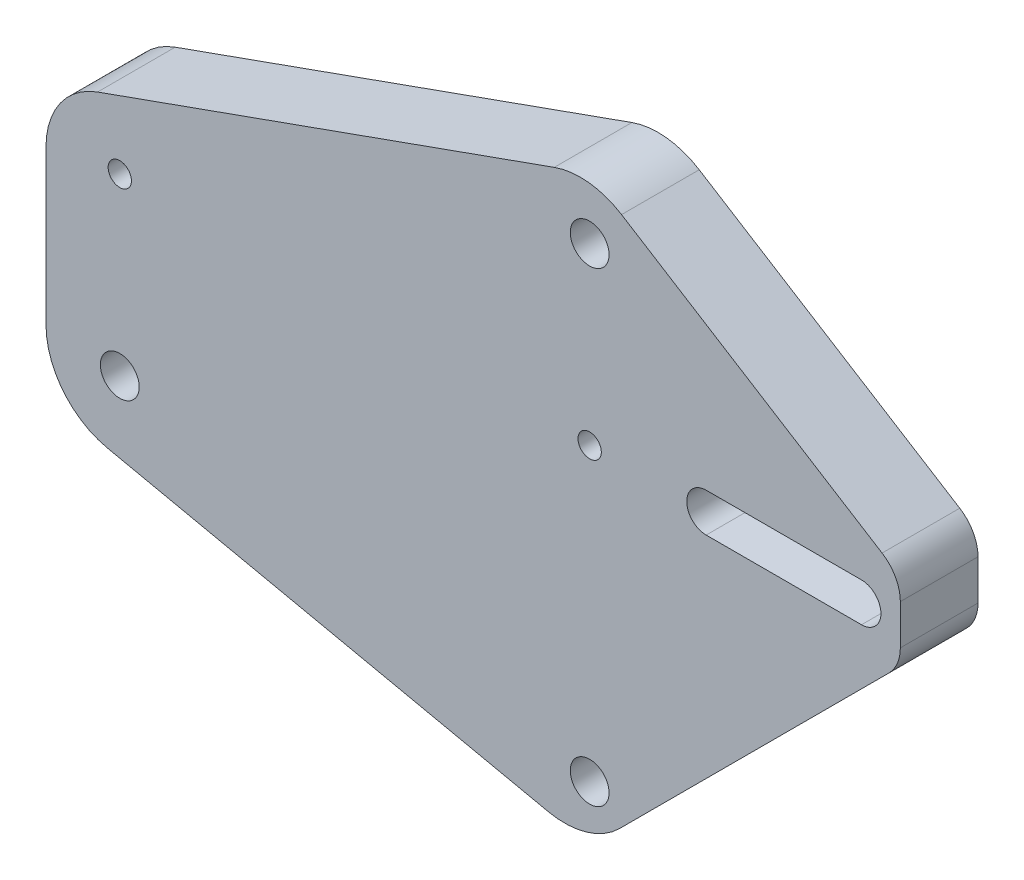
from build123d import *

# Parameters (mm, degrees)
SKETCH1_R           = 1.5
SKETCH1_R_2         = 2.5
BOSS_EXTRUDE2_DEPTH = 10


with BuildPart() as part:
    # Sketch1 → Boss-Extrude2 (new body)
    with BuildSketch(Plane.XY):
        with BuildLine():
            Line((-44.558562685, 33.371941898), (-103.36336397, 12.370227154))
            ThreePointArc((-103.36336397, 12.370227154), (-108.174155605, 8.713292405), (-110, 2.952808038))
            Line((-110, 2.952808038), (-110, -16.915842098))
            ThreePointArc((-110, -16.915842098), (-107.77666088, -23.202617548), (-102.095290887, -26.693866238))
            Line((-102.095290887, -26.693866238), (-45.319507834, -38.860105464))
            ThreePointArc((-45.319507834, -38.860105464), (-40.391993061, -38.672623949), (-36.153149135, -36.153149135))
            Line((-36.153149135, -36.153149135), (-1.464466094, -1.464466094))
            ThreePointArc((-1.464466094, -1.464466094), (-0.380602337, 0.15765065), (0, 2.071067812))
            Line((0, 2.071067812), (0, 7.228761792))
            ThreePointArc((0, 7.228761792), (-0.626787594, 9.652604454), (-2.3500053, 11.468753312))
            Line((-2.3500053, 11.468753312), (-35.895209315, 32.434505822))
            ThreePointArc((-35.895209315, 32.434505822), (-40.119407791, 33.896488075), (-44.558562685, 33.371941898))
        make_face()
        with Locations((-40, 4.649914802)):
            Circle(SKETCH1_R, mode=Mode.SUBTRACT)
        with Locations((-40, 27.149914802)):
            Circle(SKETCH1_R_2, mode=Mode.SUBTRACT)
        with Locations((-100.5, 4.649914802)):
            Circle(SKETCH1_R, mode=Mode.SUBTRACT)
        with Locations((-100.5, -17.850085198)):
            Circle(SKETCH1_R_2, mode=Mode.SUBTRACT)
        with Locations((-40, -32.850085198)):
            Circle(SKETCH1_R_2, mode=Mode.SUBTRACT)
        with BuildLine():
            Line((-25, 7.149914802), (-5, 7.149914802))
            ThreePointArc((-5, 7.149914802), (-2.5, 4.649914802), (-5, 2.149914802))
            Line((-5, 2.149914802), (-25, 2.149914802))
            ThreePointArc((-25, 2.149914802), (-27.5, 4.649914802), (-25, 7.149914802))
        make_face(mode=Mode.SUBTRACT)
    extrude(amount=BOSS_EXTRUDE2_DEPTH)


solid = part.part
